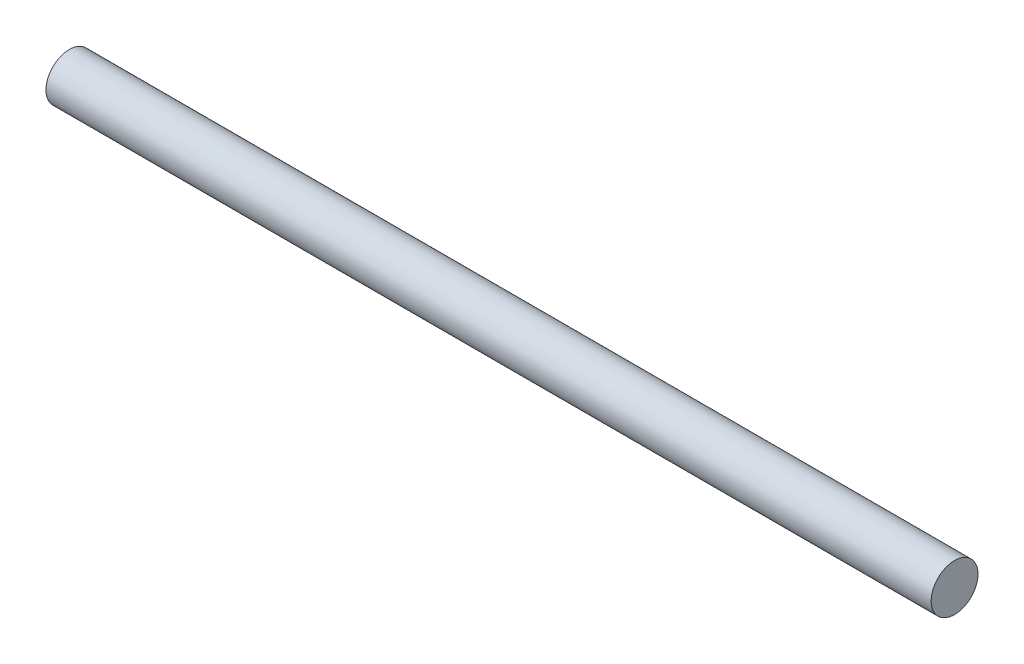
from build123d import *

# Parameters (mm, degrees)
ESBO_O1_R                = 3.96875
RESSALTO_EXTRUS_O1_DEPTH = 150


with BuildPart() as part:
    # Esboço1 → Ressalto-extrusão1 (new body)
    with BuildSketch(Plane(origin=(0, 0, 0), x_dir=(0, 0, -1), z_dir=(1, 0, 0))):
        Circle(ESBO_O1_R)
    extrude(amount=RESSALTO_EXTRUS_O1_DEPTH)


solid = part.part
